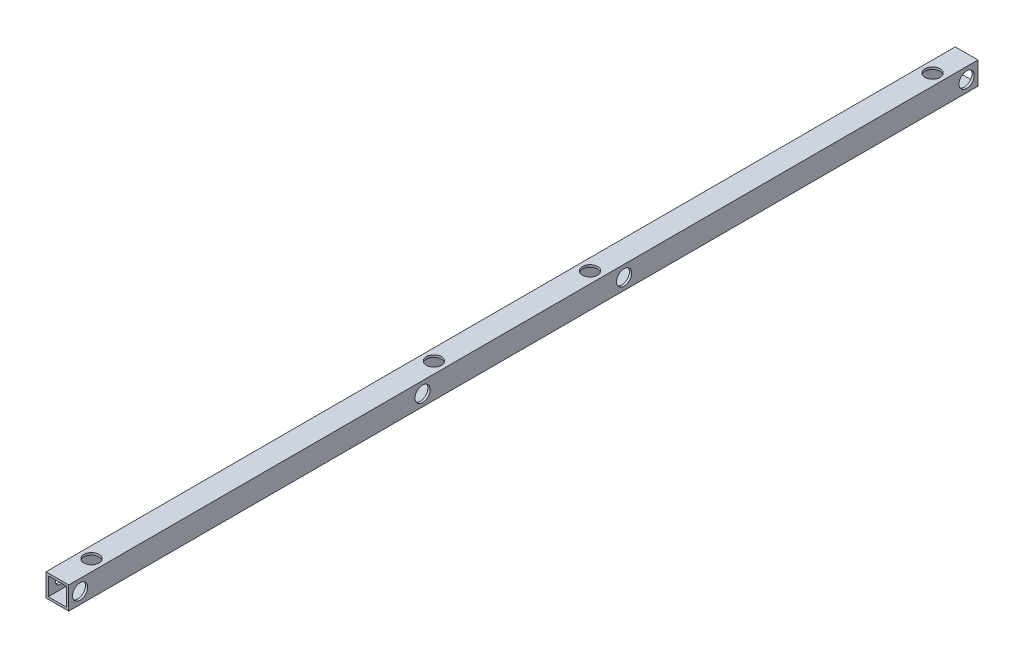
from build123d import *

# Parameters (mm, degrees)
SKETCH_1_W          = 15
SKETCH_1_H          = 15
SKETCH_1_W_2        = 12
SKETCH_1_H_2        = 12
EXTRUDE_1_DEPTH     = 600
SKETCH_2_R          = 2.7
CUT_EXTRUDE_1_DEPTH = 25
SKETCH_3_R          = 2.25
CUT_EXTRUDE_2_DEPTH = 25
SKETCH_4_R          = 5
CUT_EXTRUDE_3_DEPTH = 10
SKETCH_5_R          = 5
CUT_EXTRUDE_4_DEPTH = 10


with BuildPart() as part:
    # ｽｹｯﾁ1 → ﾎﾞｽ - 押し出し1 (new body)
    with BuildSketch(Plane.XY):
        Rectangle(SKETCH_1_W, SKETCH_1_H)
        Rectangle(SKETCH_1_W_2, SKETCH_1_H_2, mode=Mode.SUBTRACT)
    extrude(amount=EXTRUDE_1_DEPTH)

    # ｽｹｯﾁ2 → ｶｯﾄ - 押し出し1 (cut)
    with BuildSketch(Plane(origin=(7.5, 0, 0), x_dir=(0, 0, -1), z_dir=(1, 0, 0))):
        with Locations((-592.5, 0)):
            Circle(SKETCH_2_R)
        with Locations((-7.5, 0)):
            Circle(SKETCH_2_R)
        with Locations((-366.5, 0)):
            Circle(SKETCH_2_R)
        with Locations((-233.5, 0)):
            Circle(SKETCH_2_R)
    extrude(amount=-CUT_EXTRUDE_1_DEPTH, mode=Mode.SUBTRACT)

    # ｽｹｯﾁ3 → ｶｯﾄ - 押し出し2 (cut)
    with BuildSketch(Plane(origin=(0, 7.5, 0), x_dir=(1, 0, 0), z_dir=(0, 1, 0))):
        with Locations((0, -22.5)):
            Circle(SKETCH_3_R)
        with Locations((0, -577.5)):
            Circle(SKETCH_3_R)
        with Locations((0, -351.5)):
            Circle(SKETCH_3_R)
        with Locations((0, -248.5)):
            Circle(SKETCH_3_R)
    extrude(amount=-CUT_EXTRUDE_2_DEPTH, mode=Mode.SUBTRACT)

    # ｽｹｯﾁ4 → ｶｯﾄ - 押し出し3 (cut)
    with BuildSketch(Plane(origin=(0, 7.5, 0), x_dir=(1, 0, 0), z_dir=(0, 1, 0))):
        with Locations((0, -577.5)):
            Circle(SKETCH_4_R)
        with Locations((0, -351.5)):
            Circle(SKETCH_4_R)
        with Locations((0, -248.5)):
            Circle(SKETCH_4_R)
        with Locations((0, -22.5)):
            Circle(SKETCH_4_R)
    extrude(amount=-CUT_EXTRUDE_3_DEPTH, mode=Mode.SUBTRACT)

    # ｽｹｯﾁ5 → ｶｯﾄ - 押し出し4 (cut)
    with BuildSketch(Plane(origin=(7.5, 0, 0), x_dir=(0, 0, -1), z_dir=(1, 0, 0))):
        with Locations((-592.5, 0)):
            Circle(SKETCH_5_R)
        with Locations((-366.5, 0)):
            Circle(SKETCH_5_R)
        with Locations((-233.5, 0)):
            Circle(SKETCH_5_R)
        with Locations((-7.5, 0)):
            Circle(SKETCH_5_R)
    extrude(amount=-CUT_EXTRUDE_4_DEPTH, mode=Mode.SUBTRACT)


solid = part.part
